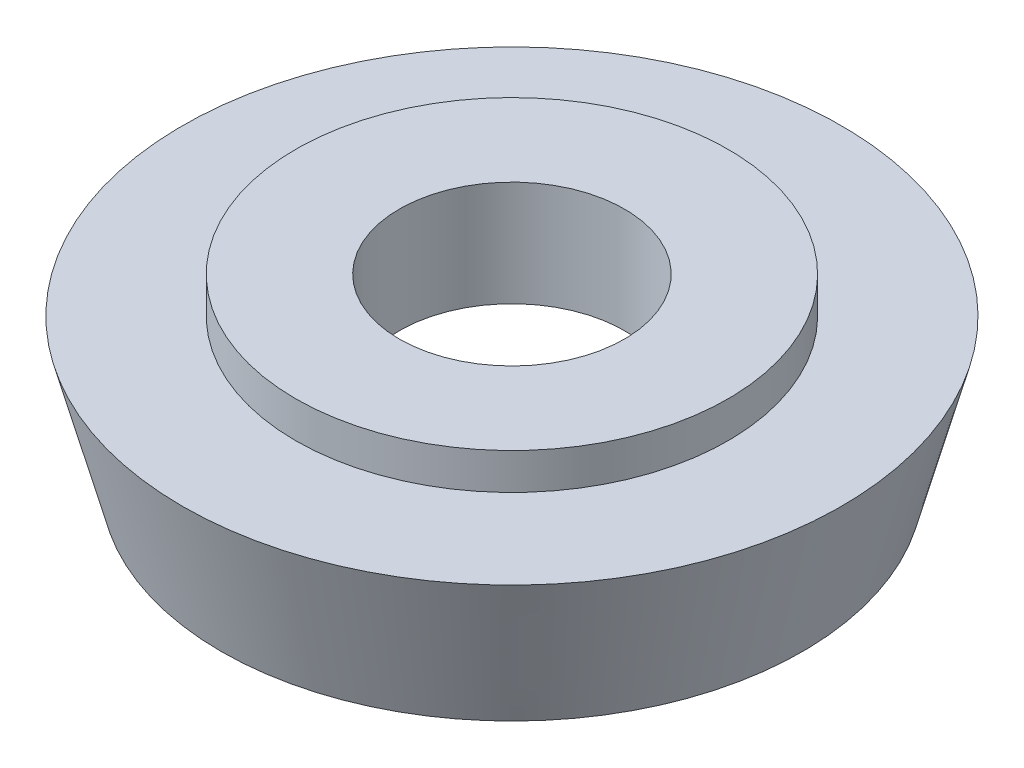
from build123d import *


with BuildPart() as part:
    # Sketch1 → Revolve1 (revolve)
    with BuildSketch(Plane.XY):
        Polygon((-1.55, 2.5), (-2.975, 2.5), (-2.975, 2), (-4.535898385, 2), (-4, 0), (-3.05, 0), (-3.05, 1.05), (-1.55, 1.05), align=None)
    revolve(axis=Axis((0, 2.5, 0), (0, -1, 0)))


solid = part.part
